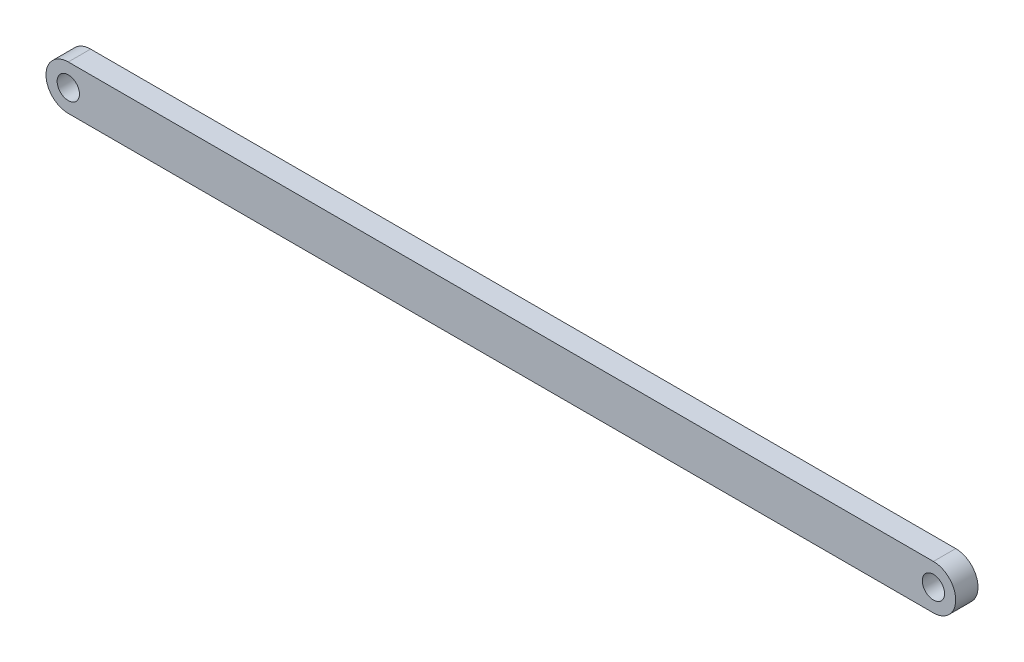
from build123d import *

# Parameters (mm, degrees)
ESQUISSE1_R      = 5
EXTRUSION3_DEPTH = 10


with BuildPart() as part:
    # Esquisse1 → Extrusion3 (new body)
    with BuildSketch(Plane.XY):
        with BuildLine():
            Line((0, 10), (388, 10))
            ThreePointArc((388, 10), (398, 0), (388, -10))
            Line((388, -10), (0, -10))
            ThreePointArc((0, -10), (-10, 0), (0, 10))
        make_face()
        with Locations(Location((0, 0, 0), (0, 0, 180))):  # turned: the seam where the file's is
            Circle(ESQUISSE1_R, mode=Mode.SUBTRACT)
        with Locations(Location((388, 0, 0), (0, 0, 180))):  # turned: the seam where the file's is
            Circle(ESQUISSE1_R, mode=Mode.SUBTRACT)
    extrude(amount=EXTRUSION3_DEPTH)


solid = part.part
